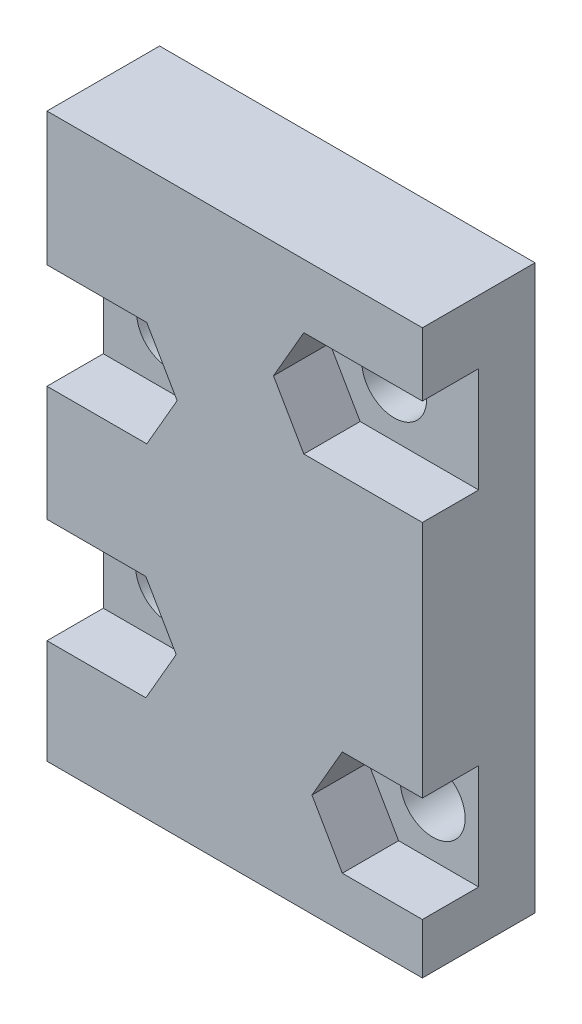
from build123d import *

# Parameters (mm, degrees)
SKETCH1_W           = 20
SKETCH1_H           = 30
BOSS_EXTRUDE1_DEPTH = 6
SKETCH2_R           = 1.72792937
CUT_EXTRUDE1_DEPTH  = 7
CUT_EXTRUDE2_DEPTH  = 3


with BuildPart() as part:
    # Sketch1 → Boss-Extrude1 (new body)
    with BuildSketch(Plane.XY):
        with Locations((10, 15)):
            Rectangle(SKETCH1_W, SKETCH1_H)
    extrude(amount=BOSS_EXTRUDE1_DEPTH)

    # Sketch2 → Cut-Extrude1 (cut, through all)
    with BuildSketch(Plane.XY.offset(6)):
        with Locations((15.5, 23.816694008)):
            Circle(SKETCH2_R)
        with Locations((3.5, 20.102573312)):
            Circle(SKETCH2_R)
        with Locations((17.55, 5.5)):
            Circle(SKETCH2_R)
        with Locations((3.45, 8.361159496)):
            Circle(SKETCH2_R)
    extrude(amount=-CUT_EXTRUDE1_DEPTH, mode=Mode.SUBTRACT)

    # Sketch3 → Cut-Extrude2 (cut)
    with BuildSketch(Plane.XY.offset(6)):
        Polygon((20, 26.616694008), (13.683419246, 26.616694008), (12.066838493, 23.816694008), (13.683419246, 21.016694008), (20, 21.016694008), align=None)
        Polygon((6.933161507, 20.102573312), (5.316580754, 22.902573312), (0, 22.902573312), (0, 17.302573312), (5.316580754, 17.302573312), align=None)
        Polygon((6.883161507, 8.361159496), (5.266580754, 11.161159496), (0, 11.161159496), (0, 5.561159496), (5.266580754, 5.561159496), align=None)
        Polygon((14.116838493, 5.5), (15.733419246, 2.7), (20, 2.7), (20, 8.3), (15.733419246, 8.3), align=None)
    extrude(amount=-CUT_EXTRUDE2_DEPTH, mode=Mode.SUBTRACT)


solid = part.part
